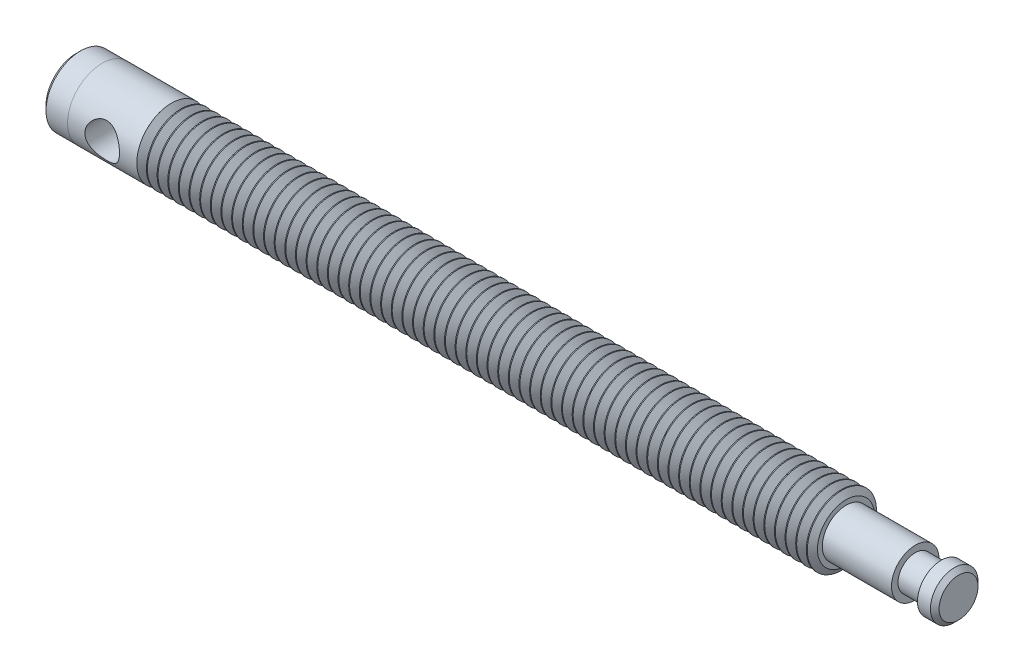
from build123d import *

# Parameters (mm, degrees)
SKETCH1_R               = 6.35
EXTRUDE1_DEPTH          = 123.825
LPATTERN2_COUNT         = 64
LPATTERN2_PITCH         = 1.95326
SKETCH3_R               = 4.365625
EXTRUDE2_DEPTH          = 12.7
SKETCH4_R               = 3.175
EXTRUDE3_DEPTH          = 4.7625
SKETCH5_R               = 4.365625
EXTRUDE4_DEPTH          = 3.175
CHAMFER1_SIZE           = 0.79375
SKETCH6_R               = 6.35
EXTRUDE5_DEPTH          = 12.7
SKETCH7_R               = 6.3373
EXTRUDE6_DEPTH          = 4.7625
CHAMFER2_SIZE           = 0.79375
SKETCH8_R               = 3.175
CUT_EXTRUDE1_DEPTH      = 7.35
CUT_EXTRUDE1_DEPTH_BACK = 7.35


with BuildPart() as part:
    # Sketch1 → Extrude1 (new body)
    with BuildSketch(Plane(origin=(0, 0, 0), x_dir=(0, 0, -1), z_dir=(1, 0, 0))):
        Circle(SKETCH1_R)
    extrude(amount=EXTRUDE1_DEPTH)

    # Sketch2 → Cut-Revolve1 (revolve, cut)
    with BuildSketch(Plane.XY):
        Polygon((-0.000263574, 6.35), (0.889, 5.08), (1.778263574, 6.35), (1.778263574, 7.9375), (-0.000263574, 7.9375), align=None)
    cut_revolve1 = revolve(axis=Axis((0, 0, 0), (1, 0, 0)), mode=Mode.SUBTRACT)

    # LPattern2: Cut-Revolve1 ×64
    with Locations(*[(i * LPATTERN2_PITCH, 0, 0) for i in range(1, LPATTERN2_COUNT)]):
        add(cut_revolve1, mode=Mode.SUBTRACT)

    # Sketch3 → Extrude2 (add)
    with BuildSketch(Plane(origin=(123.825, 0, 0), x_dir=(0, 0, -1), z_dir=(1, 0, 0))):
        Circle(SKETCH3_R)
    extrude(amount=EXTRUDE2_DEPTH)

    # Sketch4 → Extrude3 (add)
    with BuildSketch(Plane(origin=(136.525, 0, 0), x_dir=(0, 0, -1), z_dir=(1, 0, 0))):
        Circle(SKETCH4_R)
    extrude(amount=EXTRUDE3_DEPTH)

    # Sketch5 → Extrude4 (add)
    with BuildSketch(Plane(origin=(141.2875, 0, 0), x_dir=(0, 0, -1), z_dir=(1, 0, 0))):
        Circle(SKETCH5_R)
    extrude(amount=EXTRUDE4_DEPTH)

    # Chamfer1
    chamfer1_edges = [part.edges().sort_by_distance(p)[0] for p in [
        (144.4625, 0, 4.365625),
    ]]
    chamfer(chamfer1_edges, length=CHAMFER1_SIZE)


with BuildPart() as body_2:
    # Sketch6 → Extrude5 (new body)
    with BuildSketch(Plane.ZY):
        Circle(SKETCH6_R)
    extrude(amount=EXTRUDE5_DEPTH)

    # Sketch7 → Extrude6 (add)
    with BuildSketch(Plane.ZY.offset(12.7)):
        Circle(SKETCH7_R)
    extrude(amount=EXTRUDE6_DEPTH)

    # Chamfer2
    chamfer2_edges = [body_2.edges().sort_by_distance(p)[0] for p in [
        (-17.4625, 0, -6.3373),
    ]]
    chamfer(chamfer2_edges, length=CHAMFER2_SIZE)

    # Sketch8 → Cut-Extrude1 (cut, two sides)
    with BuildSketch(Plane.XY) as cut_extrude1_sk:
        with Locations((-6.35, 0)):
            Circle(SKETCH8_R)
    extrude(amount=CUT_EXTRUDE1_DEPTH, mode=Mode.SUBTRACT)
    extrude(cut_extrude1_sk.sketch, amount=-CUT_EXTRUDE1_DEPTH_BACK, mode=Mode.SUBTRACT)


solid = Compound([part.part, body_2.part])
